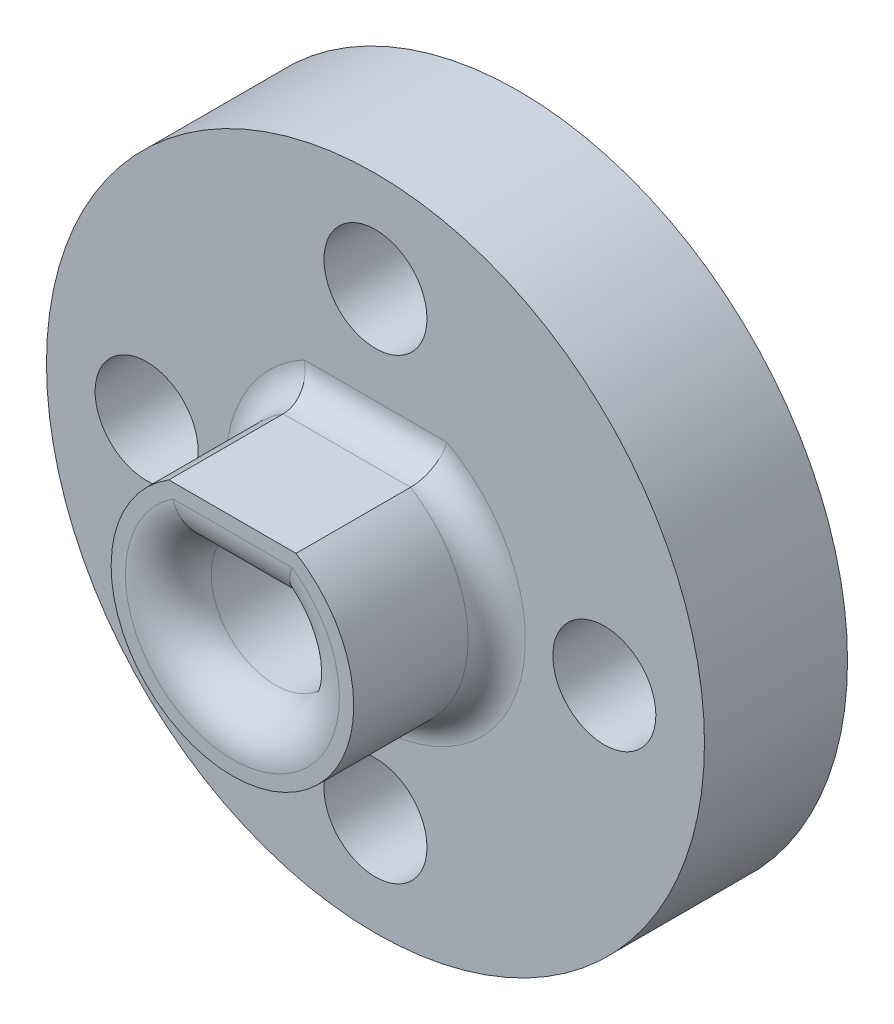
from build123d import *

# Parameters (mm, degrees)
SKETCH1_R           = 11.5
SKETCH1_R_2         = 1.8
BOSS_EXTRUDE1_DEPTH = 5
EXTRUDE_THIN1_START = 5
EXTRUDE_THIN1_DEPTH = 5
FILLET1_R           = 1
FILLET2_R           = 1.5


with BuildPart() as part:
    # Sketch1 → Boss-Extrude1 (new body)
    with BuildSketch(Plane.XY):
        Circle(SKETCH1_R)
        with Locations((0, 8)):
            Circle(SKETCH1_R_2, mode=Mode.SUBTRACT)
        with Locations((8, 0)):
            Circle(SKETCH1_R_2, mode=Mode.SUBTRACT)
        with Locations((0, -8)):
            Circle(SKETCH1_R_2, mode=Mode.SUBTRACT)
        with Locations((-8, 0)):
            Circle(SKETCH1_R_2, mode=Mode.SUBTRACT)
        with BuildLine():
            Line((1.557401682, 1.61), (-1.557401682, 1.61))
            ThreePointArc((-1.557401682, 1.61), (0, -2.24), (1.557401682, 1.61))
        make_face(mode=Mode.SUBTRACT)
    extrude(amount=BOSS_EXTRUDE1_DEPTH)

    # Sketch1_4 → Extrude-Thin1 (add)
    with BuildSketch(Plane.XY.offset(EXTRUDE_THIN1_START)):
        with BuildLine():
            Line((2.223848016, 3.61), (-2.223848016, 3.61))
            ThreePointArc((-2.223848016, 3.61), (0, -4.24), (2.223848016, 3.61))
        make_face()
        with BuildLine():
            Line((1.557401682, 1.61), (-1.557401682, 1.61))
            ThreePointArc((-1.557401682, 1.61), (0, -2.24), (1.557401682, 1.61))
        make_face(mode=Mode.SUBTRACT)
    extrude(amount=EXTRUDE_THIN1_DEPTH)

    # Fillet1
    fillet1_edges = [part.edges().sort_by_distance(p)[0] for p in [
        (0, 3.61, 5),
        (0, -4.24, 5),
    ]]
    fillet(fillet1_edges, radius=FILLET1_R)

    # Fillet2
    fillet2_edges = [part.edges().sort_by_distance(p)[0] for p in [
        (0, 1.61, 10),
        (0, -2.24, 10),
    ]]
    fillet(fillet2_edges, radius=FILLET2_R)


solid = part.part
